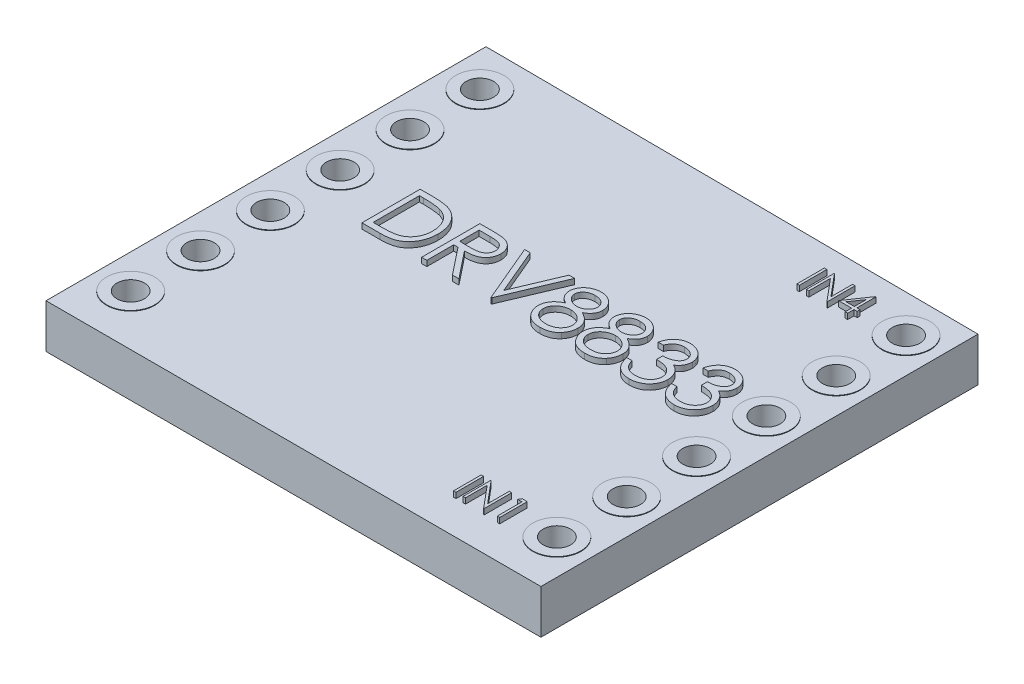
from build123d import *

# Parameters (mm, degrees)
SKETCH2_R           = 0.875
BOSS_EXTRUDE1_DEPTH = 1.6
SKETCH2_4_R         = 0.875
SKETCH2_4_R_2       = 0.5
BOSS_EXTRUDE2_DEPTH = 1.62
SKETCH3_W           = 0.08974359
SKETCH3_H           = 1
BOSS_EXTRUDE3_DEPTH = 0.2


with BuildPart() as part:
    # Sketch2 → Boss-Extrude1 (new body)
    with BuildSketch(Plane(origin=(0, 0, 0), x_dir=(1, 0, 0), z_dir=(0, 1, 0))):
        Polygon((59.478389543, 331.876942484), (41.982232799, 331.981060415), (41.478389543, 331.981060415), (41.478389543, 315.981060415), (59.478389543, 315.981060415), align=None)
        with Locations((42.728389543, 317.810394786)):
            Circle(SKETCH2_R, mode=Mode.SUBTRACT)
        with Locations((42.728389543, 320.350394786)):
            Circle(SKETCH2_R, mode=Mode.SUBTRACT)
        with Locations((42.728389543, 322.890394786)):
            Circle(SKETCH2_R, mode=Mode.SUBTRACT)
        with Locations((58.228389543, 317.810394786)):
            Circle(SKETCH2_R, mode=Mode.SUBTRACT)
        with Locations((58.228389543, 320.350394786)):
            Circle(SKETCH2_R, mode=Mode.SUBTRACT)
        with Locations((58.228389543, 322.890394786)):
            Circle(SKETCH2_R, mode=Mode.SUBTRACT)
        with Locations((42.728389543, 325.430394786)):
            Circle(SKETCH2_R, mode=Mode.SUBTRACT)
        with Locations((42.728389543, 327.970394786)):
            Circle(SKETCH2_R, mode=Mode.SUBTRACT)
        with Locations((42.728389543, 330.510394786)):
            Circle(SKETCH2_R, mode=Mode.SUBTRACT)
        with Locations((58.228389543, 325.430394786)):
            Circle(SKETCH2_R, mode=Mode.SUBTRACT)
        with Locations((58.228389543, 327.970394786)):
            Circle(SKETCH2_R, mode=Mode.SUBTRACT)
        with Locations((58.228389543, 330.510394786)):
            Circle(SKETCH2_R, mode=Mode.SUBTRACT)
    extrude(amount=BOSS_EXTRUDE1_DEPTH)

    # Sketch2_4 → Boss-Extrude2 (add)
    # profile 1 of 12: a face of its own
    with BuildSketch(Plane(origin=(0, 0, 0), x_dir=(1, 0, 0), z_dir=(0, 1, 0))):
        with Locations((42.728389543, 330.510394786)):
            Circle(SKETCH2_4_R)
        with Locations((42.728389543, 330.510394786)):
            Circle(SKETCH2_4_R_2, mode=Mode.SUBTRACT)
    # profile 2 of 12: a face of its own
    with BuildSketch(Plane(origin=(0, 0, 0), x_dir=(1, 0, 0), z_dir=(0, 1, 0))):
        with Locations((58.228389543, 330.510394786)):
            Circle(SKETCH2_4_R)
        with Locations((58.228389543, 330.510394786)):
            Circle(SKETCH2_4_R_2, mode=Mode.SUBTRACT)
    # profile 3 of 12: a face of its own
    with BuildSketch(Plane(origin=(0, 0, 0), x_dir=(1, 0, 0), z_dir=(0, 1, 0))):
        with Locations((58.228389543, 327.970394786)):
            Circle(SKETCH2_4_R)
        with Locations((58.228389543, 327.970394786)):
            Circle(SKETCH2_4_R_2, mode=Mode.SUBTRACT)
    # profile 4 of 12: a face of its own
    with BuildSketch(Plane(origin=(0, 0, 0), x_dir=(1, 0, 0), z_dir=(0, 1, 0))):
        with Locations((58.228389543, 325.430394786)):
            Circle(SKETCH2_4_R)
        with Locations((58.228389543, 325.430394786)):
            Circle(SKETCH2_4_R_2, mode=Mode.SUBTRACT)
    # profile 5 of 12: a face of its own
    with BuildSketch(Plane(origin=(0, 0, 0), x_dir=(1, 0, 0), z_dir=(0, 1, 0))):
        with Locations((58.228389543, 322.890394786)):
            Circle(SKETCH2_4_R)
        with Locations((58.228389543, 322.890394786)):
            Circle(SKETCH2_4_R_2, mode=Mode.SUBTRACT)
    # profile 6 of 12: a face of its own
    with BuildSketch(Plane(origin=(0, 0, 0), x_dir=(1, 0, 0), z_dir=(0, 1, 0))):
        with Locations((58.228389543, 320.350394786)):
            Circle(SKETCH2_4_R)
        with Locations((58.228389543, 320.350394786)):
            Circle(SKETCH2_4_R_2, mode=Mode.SUBTRACT)
    # profile 7 of 12: a face of its own
    with BuildSketch(Plane(origin=(0, 0, 0), x_dir=(1, 0, 0), z_dir=(0, 1, 0))):
        with Locations((58.228389543, 317.810394786)):
            Circle(SKETCH2_4_R)
        with Locations((58.228389543, 317.810394786)):
            Circle(SKETCH2_4_R_2, mode=Mode.SUBTRACT)
    # profile 8 of 12: a face of its own
    with BuildSketch(Plane(origin=(0, 0, 0), x_dir=(1, 0, 0), z_dir=(0, 1, 0))):
        with Locations((42.728389543, 327.970394786)):
            Circle(SKETCH2_4_R)
        with Locations((42.728389543, 327.970394786)):
            Circle(SKETCH2_4_R_2, mode=Mode.SUBTRACT)
    # profile 9 of 12: a face of its own
    with BuildSketch(Plane(origin=(0, 0, 0), x_dir=(1, 0, 0), z_dir=(0, 1, 0))):
        with Locations((42.728389543, 325.430394786)):
            Circle(SKETCH2_4_R)
        with Locations((42.728389543, 325.430394786)):
            Circle(SKETCH2_4_R_2, mode=Mode.SUBTRACT)
    # profile 10 of 12: a face of its own
    with BuildSketch(Plane(origin=(0, 0, 0), x_dir=(1, 0, 0), z_dir=(0, 1, 0))):
        with Locations((42.728389543, 322.890394786)):
            Circle(SKETCH2_4_R)
        with Locations((42.728389543, 322.890394786)):
            Circle(SKETCH2_4_R_2, mode=Mode.SUBTRACT)
    # profile 11 of 12: a face of its own
    with BuildSketch(Plane(origin=(0, 0, 0), x_dir=(1, 0, 0), z_dir=(0, 1, 0))):
        with Locations((42.728389543, 320.350394786)):
            Circle(SKETCH2_4_R)
        with Locations((42.728389543, 320.350394786)):
            Circle(SKETCH2_4_R_2, mode=Mode.SUBTRACT)
    # profile 12 of 12: a face of its own
    with BuildSketch(Plane(origin=(0, 0, 0), x_dir=(1, 0, 0), z_dir=(0, 1, 0))):
        with Locations((42.728389543, 317.810394786)):
            Circle(SKETCH2_4_R)
        with Locations((42.728389543, 317.810394786)):
            Circle(SKETCH2_4_R_2, mode=Mode.SUBTRACT)
    extrude(amount=BOSS_EXTRUDE2_DEPTH)

    # Sketch3 → Boss-Extrude3 (add)
    # profile 1 of 13: a face of its own
    with BuildSketch(Plane(origin=(0, 1.6, 0), x_dir=(1, 0, 0), z_dir=(0, 1, 0))):
        with BuildLine():
            Line((44.96926465, 323.980868602), (44.96926465, 326.097535269))
            Line((44.96926465, 326.097535269), (45.396668496, 326.097535269))
            add(Edge.make_bspline(
                [(45.396668496, 326.097535269), (45.433842598, 326.09726762), (45.505662771, 326.096750522), (45.609447441, 326.093471871), (45.705473812, 326.087671923), (45.793426065, 326.079223686), (45.873545655, 326.068850184), (45.945608242, 326.055847559), (46.009986442, 326.040493761), (46.049579866, 326.027403417), (46.068303111, 326.021213154)],
                knots=[0, 0, 0, 0, 1.314313732, 2.53924729, 3.670748893, 4.714932338, 5.66265055, 6.526160246, 7.303039223, 8, 8, 8, 8], degree=3))
            add(Edge.make_bspline(
                [(46.068303111, 326.021213154), (46.092792787, 326.011881251), (46.141216794, 325.993429061), (46.210163958, 325.958621203), (46.275070249, 325.919182803), (46.336283732, 325.875061877), (46.392406137, 325.825009152), (46.44562996, 325.771150819), (46.493777912, 325.711528347), (46.537870072, 325.647378235), (46.577624495, 325.579456184), (46.61218008, 325.507891619), (46.640878448, 325.433047974), (46.664701971, 325.355133384), (46.683477685, 325.273976527), (46.696287711, 325.189482903), (46.704736833, 325.101986441), (46.70558595, 325.042614266), (46.706016786, 325.012489195)],
                knots=[0, 0, 0, 0, 0.984719456, 1.947108742, 2.898477687, 3.838006223, 4.779231079, 5.722358779, 6.681677486, 7.655904652, 8.64651281, 9.637519902, 10.640069247, 11.656948941, 12.698408672, 13.768548281, 14.867775369, 16, 16, 16, 16], degree=3))
            add(Edge.make_bspline(
                [(46.706016786, 325.012489195), (46.705636411, 324.986326446), (46.704886841, 324.934770017), (46.698156255, 324.858787189), (46.688373433, 324.785058506), (46.673227656, 324.713935059), (46.654841374, 324.644793708), (46.63127734, 324.578371351), (46.604283492, 324.514058666), (46.572805708, 324.45272524), (46.538248775, 324.394617677), (46.501163721, 324.339841048), (46.461590101, 324.289176985), (46.419150551, 324.242472063), (46.374393504, 324.199796689), (46.327025932, 324.160794375), (46.276925611, 324.126228268), (46.224316936, 324.094740064), (46.167665182, 324.067271564), (46.105897301, 324.044030558), (46.038749874, 324.024770938), (45.966387719, 324.008701872), (45.888685806, 323.995955123), (45.805567956, 323.987412019), (45.717161871, 323.981634769), (45.656456315, 323.98112895), (45.62521083, 323.980868602)],
                knots=[0, 0, 0, 0, 1.105936401, 2.179363191, 3.223086493, 4.248585256, 5.251745608, 6.245858792, 7.225916811, 8.198733463, 9.158002045, 10.082870192, 10.993790845, 11.873723703, 12.748670949, 13.606408763, 14.465103618, 15.319838547, 16.196477973, 17.123216899, 18.106603292, 19.147568657, 20.255746949, 21.433717677, 22.679120308, 24, 24, 24, 24], degree=3))
            Line((45.62521083, 323.980868602), (44.96926465, 323.980868602))
        make_face()
        with BuildLine():
            Line((45.159221915, 324.197962619), (45.402180649, 324.197962619))
            add(Edge.make_bspline(
                [(45.402180649, 324.197962619), (45.437092568, 324.198112659), (45.504240975, 324.198401239), (45.600796049, 324.2009335), (45.689018351, 324.205071243), (45.768920407, 324.210861885), (45.840457102, 324.218523381), (45.903777942, 324.227065584), (45.95867536, 324.237707852), (45.991894591, 324.247354385), (46.007245419, 324.251812112)],
                knots=[0, 0, 0, 0, 1.375205317, 2.645023457, 3.804390687, 4.853969522, 5.800190428, 6.637939096, 7.370582563, 8, 8, 8, 8], degree=3))
            add(Edge.make_bspline(
                [(46.007245419, 324.251812112), (46.026566571, 324.258616626), (46.064747391, 324.272063128), (46.119708809, 324.296590856), (46.170966616, 324.32564487), (46.219414108, 324.357940531), (46.264364038, 324.394616922), (46.306349098, 324.43487652), (46.345284759, 324.478924218), (46.380768745, 324.526705344), (46.412523767, 324.577922506), (46.440023035, 324.632072182), (46.464123723, 324.688561062), (46.483039824, 324.748256601), (46.497865915, 324.810625127), (46.508367417, 324.875671027), (46.514907751, 324.943382155), (46.515670626, 324.989436058), (46.516059522, 325.012913207)],
                knots=[0, 0, 0, 0, 0.998632004, 1.973411704, 2.929992603, 3.868527914, 4.809262121, 5.754881198, 6.702106254, 7.672490631, 8.653608572, 9.636854334, 10.631411391, 11.644891563, 12.686317037, 13.754757253, 14.855430412, 16, 16, 16, 16], degree=3))
            add(Edge.make_bspline(
                [(46.516059522, 325.012913207), (46.515749105, 325.037668217), (46.515139289, 325.086299652), (46.507474349, 325.157655929), (46.496273217, 325.226284704), (46.480075464, 325.292190565), (46.459434409, 325.355502092), (46.433674792, 325.415869129), (46.404243075, 325.473929217), (46.369225343, 325.528342285), (46.330874008, 325.579803356), (46.288312147, 325.626947519), (46.242215962, 325.669882168), (46.19308822, 325.709275942), (46.139544355, 325.743543975), (46.082845694, 325.774197349), (46.022160455, 325.800211721), (45.979940396, 325.814047986), (45.958484067, 325.821079607)],
                knots=[0, 0, 0, 0, 1.122418816, 2.205001699, 3.251619955, 4.274784885, 5.280384055, 6.268708349, 7.249350384, 8.229342522, 9.199999885, 10.157847722, 11.105861043, 12.055065948, 13.010012805, 13.98527497, 14.976112212, 16, 16, 16, 16], degree=3))
            add(Edge.make_bspline(
                [(45.958484067, 325.821079607), (45.940733612, 325.825988113), (45.902991274, 325.836424944), (45.841402646, 325.847809812), (45.77208777, 325.857851581), (45.694738903, 325.866353348), (45.609444216, 325.872453775), (45.516138109, 325.877032618), (45.414780253, 325.880120915), (45.344517483, 325.8803318), (45.30805004, 325.880441252)],
                knots=[0, 0, 0, 0, 0.674548936, 1.434276114, 2.292660221, 3.240891867, 4.284742987, 5.42552168, 6.663806718, 8, 8, 8, 8], degree=3))
            Line((45.30805004, 325.880441252), (45.159221915, 325.880441252))
            Line((45.159221915, 325.880441252), (45.159221915, 324.197962619))
        make_face(mode=Mode.SUBTRACT)
    # profile 2 of 13: a face of its own
    with BuildSketch(Plane(origin=(0, 1.6, 0), x_dir=(1, 0, 0), z_dir=(0, 1, 0))):
        with BuildLine():
            Line((47.140204821, 326.097535269), (47.563792561, 326.097535269))
            add(Edge.make_bspline(
                [(47.563792561, 326.097535269), (47.592059815, 326.097441177), (47.646336074, 326.097260509), (47.72409229, 326.096253119), (47.794744867, 326.09336577), (47.858256865, 326.090881055), (47.914627119, 326.086350215), (47.96402848, 326.082019728), (48.006233421, 326.076350895), (48.031782103, 326.071086187), (48.043349853, 326.06870247)],
                knots=[0, 0, 0, 0, 1.410062039, 2.707475311, 3.878576406, 4.937260626, 5.877586885, 6.699081471, 7.410979367, 8, 8, 8, 8], degree=3))
            add(Edge.make_bspline(
                [(48.043349853, 326.06870247), (48.058835763, 326.064876283), (48.089477229, 326.057305533), (48.133594649, 326.041303774), (48.175634264, 326.022786192), (48.215421444, 326.001036704), (48.252756899, 325.975893861), (48.288025591, 325.947791711), (48.321387562, 325.916884019), (48.351493595, 325.88239152), (48.379880546, 325.846204678), (48.403822239, 325.807074311), (48.424460634, 325.766155197), (48.440892327, 325.723031187), (48.454123292, 325.678120497), (48.463452494, 325.63101632), (48.46904726, 325.581933254), (48.469616858, 325.548454899), (48.469905675, 325.53147958)],
                knots=[0, 0, 0, 0, 1.027469482, 2.033020251, 3.019912614, 3.986113645, 4.951240523, 5.91722682, 6.890402269, 7.87763091, 8.8651537, 9.85103654, 10.82876324, 11.815024772, 12.821070561, 13.842952187, 14.906261191, 16, 16, 16, 16], degree=3))
            add(Edge.make_bspline(
                [(48.469905675, 325.53147958), (48.469017281, 325.503276445), (48.467283794, 325.448244825), (48.45112147, 325.368379434), (48.424647098, 325.29387923), (48.388165871, 325.224838016), (48.341708379, 325.162601578), (48.285873862, 325.107936874), (48.220631173, 325.062192736), (48.159895349, 325.030471278), (48.10624438, 325.010155567), (48.062076615, 324.995861197), (48.013897062, 324.984817056), (47.962167341, 324.974923072), (47.906672178, 324.967453238), (47.847544582, 324.961982202), (47.784742386, 324.958562849), (47.741599234, 324.958053636), (47.719404874, 324.957791679)],
                knots=[0, 0, 0, 0, 1.260483769, 2.459530307, 3.627416485, 4.787058657, 5.939039949, 7.08810263, 8.267026773, 9.491475466, 10.141966685, 10.831826277, 11.566392101, 12.351337768, 13.187381173, 14.07005841, 15.007169909, 16, 16, 16, 16], degree=3))
            Line((47.719404874, 324.957791679), (48.497042427, 323.980868602))
            Line((48.497042427, 323.980868602), (48.262139917, 323.980868602))
            Line((48.262139917, 323.980868602), (47.484502363, 324.957791679))
            Line((47.484502363, 324.957791679), (47.330162086, 324.957791679))
            Line((47.330162086, 324.957791679), (47.330162086, 323.980868602))
            Line((47.330162086, 323.980868602), (47.140204821, 323.980868602))
            Line((47.140204821, 323.980868602), (47.140204821, 326.097535269))
        make_face()
        with BuildLine():
            Line((47.330162086, 325.880441252), (47.330162086, 325.174885696))
            Line((47.330162086, 325.174885696), (47.717708827, 325.171917614))
            add(Edge.make_bspline(
                [(47.717708827, 325.171917614), (47.735803327, 325.171909609), (47.770875621, 325.171894093), (47.821615547, 325.174309377), (47.868859614, 325.177057003), (47.912427117, 325.181259702), (47.952337517, 325.186675993), (47.988570867, 325.193451131), (48.021186313, 325.201344521), (48.059224953, 325.213561695), (48.101701331, 325.232917716), (48.14786369, 325.261078755), (48.187174628, 325.296499127), (48.220386859, 325.337002122), (48.247074658, 325.38153452), (48.265890043, 325.429562515), (48.27782952, 325.479873624), (48.279237736, 325.514452766), (48.27994841, 325.531903592)],
                knots=[0, 0, 0, 0, 1.146690395, 2.22261258, 3.21895312, 4.145990853, 4.996080663, 5.770904154, 6.481378293, 7.121626537, 8.300444488, 9.431385265, 10.535395872, 11.636531494, 12.74115979, 13.810798291, 14.895190096, 16, 16, 16, 16], degree=3))
            add(Edge.make_bspline(
                [(48.27994841, 325.531903592), (48.279221413, 325.548925567), (48.277780771, 325.582656912), (48.266018896, 325.632039295), (48.246128651, 325.678646451), (48.21932425, 325.722288782), (48.186667618, 325.761904156), (48.148375417, 325.795799339), (48.105494657, 325.823769253), (48.06541636, 325.841642617), (48.029593765, 325.852600814), (47.998491066, 325.860312232), (47.963347458, 325.866507696), (47.9239923, 325.871471619), (47.880593599, 325.87573818), (47.83293192, 325.878611875), (47.781323486, 325.880313593), (47.745553675, 325.880397709), (47.727037086, 325.880441252)],
                knots=[0, 0, 0, 0, 1.101028733, 2.181837193, 3.264309656, 4.369019818, 5.486613113, 6.575447106, 7.666700264, 8.788928104, 9.402425223, 10.0903467, 10.862060571, 11.710948788, 12.657782767, 13.684531032, 14.801375019, 16, 16, 16, 16], degree=3))
            Line((47.727037086, 325.880441252), (47.330162086, 325.880441252))
        make_face(mode=Mode.SUBTRACT)
    # profile 3 of 13: a face of its own
    with BuildSketch(Plane(origin=(0, 1.6, 0), x_dir=(1, 0, 0), z_dir=(0, 1, 0))):
        Polygon((48.768409949, 326.097535269), (48.97193559, 326.097535269), (49.677491145, 324.429473036), (50.383046701, 326.097535269), (50.586572342, 326.097535269), (49.691059522, 323.980868602), (49.663922769, 323.980868602), align=None)
    # profile 4 of 13: a face of its own
    with BuildSketch(Plane(origin=(0, 1.6, 0), x_dir=(1, 0, 0), z_dir=(0, 1, 0))):
        with BuildLine():
            add(Edge.make_bspline(
                [(51.805606129, 325.160045285), (51.822931679, 325.151011378), (51.856722288, 325.133392243), (51.904847552, 325.105022362), (51.948828862, 325.07512235), (51.989886488, 325.045104473), (52.027299086, 325.013819141), (52.060648326, 324.981141946), (52.090757982, 324.947888541), (52.117020846, 324.913495828), (52.140120838, 324.878055179), (52.16008532, 324.841473571), (52.177150009, 324.803831174), (52.190674262, 324.764717091), (52.20181506, 324.724705885), (52.209480783, 324.683280915), (52.213603395, 324.640715147), (52.214382821, 324.61194765), (52.21477747, 324.59738169)],
                knots=[0, 0, 0, 0, 1.272397273, 2.481599622, 3.635517121, 4.734568067, 5.792894095, 6.808321871, 7.773003508, 8.711915296, 9.623354172, 10.525449501, 11.423591555, 12.311487226, 13.218079475, 14.126165749, 15.051214107, 16, 16, 16, 16], degree=3))
            add(Edge.make_bspline(
                [(52.21477747, 324.59738169), (52.214310944, 324.577002585), (52.213387515, 324.53666469), (52.205344191, 324.477128232), (52.19330158, 324.419305868), (52.175715399, 324.363210276), (52.152907777, 324.309150989), (52.124800357, 324.25708173), (52.092983105, 324.206149101), (52.06743056, 324.174810701), (52.054501028, 324.158953538)],
                knots=[0, 0, 0, 0, 1.025265484, 2.029385089, 3.018602448, 3.995076438, 4.983346944, 5.966715145, 6.97116228, 8, 8, 8, 8], degree=3))
            add(Edge.make_bspline(
                [(52.054501028, 324.158953538), (52.037666589, 324.140451589), (52.004205738, 324.103676325), (51.946884634, 324.055929882), (51.883976162, 324.015804296), (51.815723741, 323.983103674), (51.742309818, 323.95765175), (51.663750034, 323.939362227), (51.579891237, 323.928886282), (51.522254119, 323.927371965), (51.492685456, 323.926595098)],
                knots=[0, 0, 0, 0, 0.954267603, 1.896743057, 2.838368354, 3.796610408, 4.779680527, 5.799409237, 6.871065594, 8, 8, 8, 8], degree=3))
            add(Edge.make_bspline(
                [(51.492685456, 323.926595098), (51.46425355, 323.927292073), (51.408927948, 323.928648315), (51.328399136, 323.937837328), (51.253334232, 323.953940848), (51.183296775, 323.975981159), (51.118708994, 324.004653059), (51.059754928, 324.040339097), (51.005584002, 324.081602874), (50.957840182, 324.129629483), (50.915453361, 324.181069244), (50.878219348, 324.234138074), (50.847271215, 324.288840819), (50.821068638, 324.344361813), (50.801009882, 324.401479249), (50.787117164, 324.459899257), (50.778294103, 324.519519795), (50.777120178, 324.559755605), (50.776529607, 324.579997208)],
                knots=[0, 0, 0, 0, 1.256902934, 2.445805442, 3.576955095, 4.645999104, 5.686449165, 6.692658513, 7.68621702, 8.689161843, 9.678783111, 10.630372946, 11.551080876, 12.453998257, 13.34127905, 14.221779781, 15.105423033, 16, 16, 16, 16], degree=3))
            add(Edge.make_bspline(
                [(50.776529607, 324.579997208), (50.776879087, 324.594849672), (50.777569784, 324.624203383), (50.782350335, 324.667570453), (50.790035928, 324.709780496), (50.80047379, 324.750989422), (50.814619792, 324.79089722), (50.831699558, 324.829692983), (50.851615549, 324.867420509), (50.874645587, 324.904286118), (50.901437763, 324.939773252), (50.931774827, 324.974484163), (50.96626311, 325.007880244), (51.004518932, 325.04036952), (51.046105106, 325.072528324), (51.092101803, 325.102618693), (51.14128967, 325.132770891), (51.176248177, 325.15079783), (51.194181183, 325.160045285)],
                knots=[0, 0, 0, 0, 0.941657376, 1.861047343, 2.762797495, 3.66048619, 4.553285746, 5.444104102, 6.34607688, 7.256116206, 8.197091036, 9.162375105, 10.176350973, 11.237807142, 12.343728897, 13.50695164, 14.721116704, 16, 16, 16, 16], degree=3))
            add(Edge.make_bspline(
                [(51.194181183, 325.160045285), (51.169633066, 325.17343155), (51.12210104, 325.199351105), (51.059163807, 325.246974174), (51.005103763, 325.298552995), (50.961406862, 325.355176728), (50.927012705, 325.415076505), (50.90341574, 325.477877552), (50.887452152, 325.542415393), (50.885870804, 325.586506283), (50.885076616, 325.608649719)],
                knots=[0, 0, 0, 0, 1.166880483, 2.259407225, 3.286803203, 4.280235371, 5.237608625, 6.161067461, 7.076446754, 8, 8, 8, 8], degree=3))
            add(Edge.make_bspline(
                [(50.885076616, 325.608649719), (50.886065658, 325.631205861), (50.888053805, 325.676547641), (50.904130385, 325.744042773), (50.930328711, 325.810334696), (50.965961885, 325.875102103), (51.010343678, 325.936152947), (51.063590874, 325.990908662), (51.124431916, 326.038873225), (51.192563102, 326.079135958), (51.265882159, 326.111904171), (51.343240716, 326.134509217), (51.423290928, 326.14928725), (51.477778597, 326.150960417), (51.505405809, 326.151808773)],
                knots=[0, 0, 0, 0, 0.888701115, 1.786444228, 2.72001202, 3.692817113, 4.693886446, 5.687152267, 6.695133018, 7.739871481, 8.800368666, 9.853104506, 10.91144658, 12, 12, 12, 12], degree=3))
            add(Edge.make_bspline(
                [(51.505405809, 326.151808773), (51.532320021, 326.15093408), (51.585391781, 326.149209285), (51.663402817, 326.134823887), (51.738045481, 326.110796987), (51.809062369, 326.078202), (51.875182117, 326.038053707), (51.933603514, 325.989430321), (51.985209408, 325.934916145), (52.027896161, 325.873883814), (52.063070861, 325.809365277), (52.087564263, 325.741860229), (52.103259028, 325.672827227), (52.105238634, 325.626116624), (52.106230462, 325.602713554)],
                knots=[0, 0, 0, 0, 1.072916533, 2.115669174, 3.151510826, 4.193348718, 5.225979165, 6.227137561, 7.216255879, 8.211077061, 9.189680878, 10.138522389, 11.067357538, 12, 12, 12, 12], degree=3))
            add(Edge.make_bspline(
                [(52.106230462, 325.602713554), (52.105362894, 325.579746715), (52.103659041, 325.534641147), (52.08932622, 325.46888749), (52.065188168, 325.407309399), (52.032232175, 325.349208138), (51.989278666, 325.295637423), (51.936901003, 325.245916034), (51.875516776, 325.199635523), (51.829397097, 325.173518055), (51.805606129, 325.160045285)],
                knots=[0, 0, 0, 0, 0.975232327, 1.915300861, 2.843280834, 3.77672583, 4.742871857, 5.749627742, 6.839139064, 8, 8, 8, 8], degree=3))
        make_face()
        with BuildLine():
            add(Edge.make_bspline(
                [(51.494805515, 325.934714756), (51.479958123, 325.93432079), (51.450910132, 325.933550019), (51.408317555, 325.929523129), (51.367815218, 325.921689517), (51.328979948, 325.911264201), (51.29234419, 325.897180513), (51.257410388, 325.880613055), (51.224773088, 325.860470815), (51.1940383, 325.837876186), (51.166369974, 325.813024762), (51.141813888, 325.787132656), (51.12141641, 325.759691347), (51.104095358, 325.731383435), (51.091527488, 325.701368753), (51.08211479, 325.670567518), (51.075751853, 325.6385905), (51.075275065, 325.616736515), (51.07503388, 325.605681637)],
                knots=[0, 0, 0, 0, 1.203892937, 2.355340988, 3.463153438, 4.544400666, 5.610487187, 6.640501085, 7.674077295, 8.714426146, 9.728707835, 10.68524104, 11.601827946, 12.495867327, 13.368432065, 14.231010473, 15.105153427, 16, 16, 16, 16], degree=3))
            add(Edge.make_bspline(
                [(51.07503388, 325.605681637), (51.075449574, 325.594626281), (51.076271044, 325.57277931), (51.082624145, 325.540517762), (51.092092814, 325.508815153), (51.107000595, 325.478425317), (51.124881202, 325.448294047), (51.146949857, 325.419174407), (51.173250364, 325.390965055), (51.202900292, 325.363905926), (51.235201556, 325.338567151), (51.269421429, 325.316570036), (51.305130438, 325.298164645), (51.341961689, 325.282846386), (51.380290559, 325.270938662), (51.419882189, 325.262490957), (51.460743231, 325.257240416), (51.488429582, 325.256613265), (51.502437727, 325.256295953)],
                knots=[0, 0, 0, 0, 0.873023192, 1.725219244, 2.590779336, 3.480155217, 4.391973325, 5.357036234, 6.360879153, 7.436073238, 8.526419356, 9.601555421, 10.645666583, 11.697338044, 12.750135903, 13.812665442, 14.89329948, 16, 16, 16, 16], degree=3))
            add(Edge.make_bspline(
                [(51.502437727, 325.256295953), (51.520429456, 325.25682383), (51.556235212, 325.257874369), (51.609018427, 325.267641984), (51.660340121, 325.283006515), (51.709651744, 325.304028019), (51.755676898, 325.330412486), (51.796703987, 325.362001026), (51.83238306, 325.398064246), (51.862343334, 325.438040723), (51.885572146, 325.480586684), (51.90365562, 325.523283051), (51.914215498, 325.566585353), (51.915592884, 325.595593945), (51.916273197, 325.609921754)],
                knots=[0, 0, 0, 0, 1.076279235, 2.141928126, 3.20205304, 4.278698113, 5.344010996, 6.36967002, 7.368914609, 8.37248503, 9.349703398, 10.264243087, 11.142681841, 12, 12, 12, 12], degree=3))
            add(Edge.make_bspline(
                [(51.916273197, 325.609921754), (51.915951525, 325.619977757), (51.915313054, 325.639937481), (51.910051591, 325.669412587), (51.901357635, 325.698217145), (51.889587106, 325.726589109), (51.874099278, 325.754130409), (51.855736174, 325.78127399), (51.833429832, 325.807409238), (51.808394846, 325.833145213), (51.780004052, 325.85696317), (51.748312162, 325.877908923), (51.713481656, 325.895696396), (51.67551171, 325.910143405), (51.63454216, 325.920994254), (51.590761708, 325.929120046), (51.543805304, 325.933699975), (51.511493026, 325.934369159), (51.494805515, 325.934714756)],
                knots=[0, 0, 0, 0, 0.814439003, 1.616544685, 2.417341072, 3.248991801, 4.09997495, 4.973547432, 5.9003056, 6.880240646, 7.880314356, 8.896779544, 9.951930927, 11.043077905, 12.18215768, 13.381699519, 14.647792085, 16, 16, 16, 16], degree=3))
        make_face(mode=Mode.SUBTRACT)
        with BuildLine():
            add(Edge.make_bspline(
                [(51.507101856, 325.039201936), (51.488278167, 325.038867114), (51.451350681, 325.038210277), (51.397250539, 325.030899008), (51.345329815, 325.020721232), (51.295763568, 325.005281153), (51.248572728, 324.985205181), (51.20350183, 324.961054292), (51.16089567, 324.932506238), (51.121342593, 324.899923714), (51.085224198, 324.864811568), (51.053535703, 324.82764161), (51.026625298, 324.78910465), (51.004954712, 324.748711254), (50.987167617, 324.707316746), (50.97548732, 324.663890248), (50.967999333, 324.619266613), (50.966993836, 324.588931696), (50.966486872, 324.573637032)],
                knots=[0, 0, 0, 0, 1.140299081, 2.23698856, 3.303958914, 4.344563908, 5.37730929, 6.408454204, 7.439741482, 8.480804886, 9.510774543, 10.48932336, 11.43758569, 12.353841022, 13.263987381, 14.161954604, 15.073269652, 16, 16, 16, 16], degree=3))
            add(Edge.make_bspline(
                [(50.966486872, 324.573637032), (50.967311319, 324.554628817), (50.968947002, 324.516916963), (50.98192316, 324.461180249), (51.00274846, 324.407222754), (51.031792281, 324.355484192), (51.067756004, 324.307133413), (51.111980106, 324.264988297), (51.161716232, 324.227540545), (51.218647219, 324.197253747), (51.280833958, 324.173066382), (51.348259909, 324.156401585), (51.419957407, 324.145369851), (51.46946297, 324.144258189), (51.494805515, 324.143689115)],
                knots=[0, 0, 0, 0, 0.898778495, 1.783155532, 2.693654817, 3.627872908, 4.583023416, 5.533784346, 6.509005473, 7.520592997, 8.575161974, 9.658835044, 10.801527049, 12, 12, 12, 12], degree=3))
            add(Edge.make_bspline(
                [(51.494805515, 324.143689115), (51.51461169, 324.144069395), (51.55320047, 324.144810301), (51.609495306, 324.151350374), (51.662620342, 324.161721814), (51.712472559, 324.17680672), (51.759610024, 324.195221706), (51.803233528, 324.218911488), (51.844465304, 324.245855036), (51.881273607, 324.277821636), (51.9147975, 324.311978282), (51.944027634, 324.348137023), (51.969401962, 324.385315143), (51.98931735, 324.424352817), (52.005238465, 324.464501094), (52.01668271, 324.506130189), (52.02374404, 324.549367782), (52.024458201, 324.578698173), (52.024820205, 324.593565584)],
                knots=[0, 0, 0, 0, 1.224942928, 2.386581632, 3.501229538, 4.569074225, 5.605009692, 6.626002462, 7.634866581, 8.645888296, 9.63523824, 10.59253846, 11.518950513, 12.414518923, 13.29783783, 14.186679152, 15.080837789, 16, 16, 16, 16], degree=3))
            add(Edge.make_bspline(
                [(52.024820205, 324.593565584), (52.024272383, 324.60800569), (52.023192172, 324.636479057), (52.016336173, 324.678671194), (52.004291809, 324.719433849), (51.987765241, 324.759257424), (51.96576342, 324.797335018), (51.939852475, 324.834658607), (51.908589841, 324.870192266), (51.873264128, 324.904211996), (51.834765614, 324.935669132), (51.793843103, 324.963496911), (51.750811595, 324.986932715), (51.705762148, 325.005992691), (51.658794793, 325.020983208), (51.609944074, 325.031455262), (51.559152798, 325.038046927), (51.524648186, 325.038812583), (51.507101856, 325.039201936)],
                knots=[0, 0, 0, 0, 0.917430815, 1.809013306, 2.70690318, 3.612392954, 4.541220862, 5.495268465, 6.494511384, 7.542276156, 8.608045339, 9.649016899, 10.681629292, 11.715607085, 12.752076957, 13.808767841, 14.885711793, 16, 16, 16, 16], degree=3))
        make_face(mode=Mode.SUBTRACT)
    # profile 5 of 13: a face of its own
    with BuildSketch(Plane(origin=(0, 1.6, 0), x_dir=(1, 0, 0), z_dir=(0, 1, 0))):
        with BuildLine():
            add(Edge.make_bspline(
                [(53.433811258, 325.160045285), (53.451136808, 325.151011378), (53.484927416, 325.133392243), (53.53305268, 325.105022362), (53.57703399, 325.07512235), (53.618091616, 325.045104473), (53.655504214, 325.013819141), (53.688853454, 324.981141946), (53.71896311, 324.947888541), (53.745225974, 324.913495828), (53.768325966, 324.878055179), (53.788290448, 324.841473571), (53.805355137, 324.803831174), (53.818879391, 324.764717091), (53.830020188, 324.724705885), (53.837685911, 324.683280915), (53.841808524, 324.640715147), (53.842587949, 324.61194765), (53.842982598, 324.59738169)],
                knots=[0, 0, 0, 0, 1.272397273, 2.481599622, 3.635517121, 4.734568067, 5.792894095, 6.808321871, 7.773003508, 8.711915296, 9.623354172, 10.525449501, 11.423591555, 12.311487226, 13.218079475, 14.126165749, 15.051214107, 16, 16, 16, 16], degree=3))
            add(Edge.make_bspline(
                [(53.842982598, 324.59738169), (53.842516073, 324.577002585), (53.841592643, 324.53666469), (53.833549319, 324.477128232), (53.821506709, 324.419305868), (53.803920527, 324.363210276), (53.781112905, 324.309150989), (53.753005486, 324.25708173), (53.721188233, 324.206149101), (53.695635688, 324.174810701), (53.682706156, 324.158953538)],
                knots=[0, 0, 0, 0, 1.025265484, 2.029385089, 3.018602448, 3.995076438, 4.983346944, 5.966715145, 6.97116228, 8, 8, 8, 8], degree=3))
            add(Edge.make_bspline(
                [(53.682706156, 324.158953538), (53.665871717, 324.140451589), (53.632410866, 324.103676325), (53.575089762, 324.055929882), (53.51218129, 324.015804296), (53.44392887, 323.983103674), (53.370514946, 323.95765175), (53.291955163, 323.939362227), (53.208096365, 323.928886282), (53.150459247, 323.927371965), (53.120890585, 323.926595098)],
                knots=[0, 0, 0, 0, 0.954267603, 1.896743057, 2.838368354, 3.796610408, 4.779680527, 5.799409237, 6.871065594, 8, 8, 8, 8], degree=3))
            add(Edge.make_bspline(
                [(53.120890585, 323.926595098), (53.092458678, 323.927292073), (53.037133076, 323.928648315), (52.956604264, 323.937837328), (52.88153936, 323.953940848), (52.811501903, 323.975981159), (52.746914122, 324.004653059), (52.687960056, 324.040339097), (52.63378913, 324.081602874), (52.58604531, 324.129629483), (52.543658489, 324.181069244), (52.506424476, 324.234138074), (52.475476343, 324.288840819), (52.449273766, 324.344361813), (52.42921501, 324.401479249), (52.415322292, 324.459899257), (52.406499231, 324.519519795), (52.405325306, 324.559755605), (52.404734735, 324.579997208)],
                knots=[0, 0, 0, 0, 1.256902934, 2.445805442, 3.576955095, 4.645999104, 5.686449165, 6.692658513, 7.68621702, 8.689161843, 9.678783111, 10.630372946, 11.551080876, 12.453998257, 13.34127905, 14.221779781, 15.105423033, 16, 16, 16, 16], degree=3))
            add(Edge.make_bspline(
                [(52.404734735, 324.579997208), (52.405084216, 324.594849672), (52.405774912, 324.624203383), (52.410555463, 324.667570453), (52.418241057, 324.709780496), (52.428678919, 324.750989422), (52.44282492, 324.79089722), (52.459904687, 324.829692983), (52.479820677, 324.867420509), (52.502850715, 324.904286118), (52.529642891, 324.939773252), (52.559979956, 324.974484163), (52.594468238, 325.007880244), (52.63272406, 325.04036952), (52.674310234, 325.072528324), (52.720306931, 325.102618693), (52.769494798, 325.132770891), (52.804453305, 325.15079783), (52.822386311, 325.160045285)],
                knots=[0, 0, 0, 0, 0.941657376, 1.861047343, 2.762797495, 3.66048619, 4.553285746, 5.444104102, 6.34607688, 7.256116206, 8.197091036, 9.162375105, 10.176350973, 11.237807142, 12.343728897, 13.50695164, 14.721116704, 16, 16, 16, 16], degree=3))
            add(Edge.make_bspline(
                [(52.822386311, 325.160045285), (52.797838194, 325.17343155), (52.750306168, 325.199351105), (52.687368935, 325.246974174), (52.633308891, 325.298552995), (52.589611991, 325.355176728), (52.555217834, 325.415076505), (52.531620868, 325.477877552), (52.51565728, 325.542415393), (52.514075932, 325.586506283), (52.513281744, 325.608649719)],
                knots=[0, 0, 0, 0, 1.166880483, 2.259407225, 3.286803203, 4.280235371, 5.237608625, 6.161067461, 7.076446754, 8, 8, 8, 8], degree=3))
            add(Edge.make_bspline(
                [(52.513281744, 325.608649719), (52.514270786, 325.631205861), (52.516258933, 325.676547641), (52.532335513, 325.744042773), (52.558533839, 325.810334696), (52.594167013, 325.875102103), (52.638548806, 325.936152947), (52.691796003, 325.990908662), (52.752637044, 326.038873225), (52.82076823, 326.079135958), (52.894087287, 326.111904171), (52.971445844, 326.134509217), (53.051496056, 326.14928725), (53.105983725, 326.150960417), (53.133610937, 326.151808773)],
                knots=[0, 0, 0, 0, 0.888701115, 1.786444228, 2.72001202, 3.692817113, 4.693886446, 5.687152267, 6.695133018, 7.739871481, 8.800368666, 9.853104506, 10.91144658, 12, 12, 12, 12], degree=3))
            add(Edge.make_bspline(
                [(53.133610937, 326.151808773), (53.160525149, 326.15093408), (53.213596909, 326.149209285), (53.291607945, 326.134823887), (53.366250609, 326.110796987), (53.437267497, 326.078202), (53.503387245, 326.038053707), (53.561808642, 325.989430321), (53.613414537, 325.934916145), (53.656101289, 325.873883814), (53.691275989, 325.809365277), (53.715769391, 325.741860229), (53.731464156, 325.672827227), (53.733443762, 325.626116624), (53.73443559, 325.602713554)],
                knots=[0, 0, 0, 0, 1.072916533, 2.115669174, 3.151510826, 4.193348718, 5.225979165, 6.227137561, 7.216255879, 8.211077061, 9.189680878, 10.138522389, 11.067357538, 12, 12, 12, 12], degree=3))
            add(Edge.make_bspline(
                [(53.73443559, 325.602713554), (53.733568022, 325.579746715), (53.731864169, 325.534641147), (53.717531348, 325.46888749), (53.693393297, 325.407309399), (53.660437303, 325.349208138), (53.617483794, 325.295637423), (53.565106131, 325.245916034), (53.503721904, 325.199635523), (53.457602225, 325.173518055), (53.433811258, 325.160045285)],
                knots=[0, 0, 0, 0, 0.975232327, 1.915300861, 2.843280834, 3.77672583, 4.742871857, 5.749627742, 6.839139064, 8, 8, 8, 8], degree=3))
        make_face()
        with BuildLine():
            add(Edge.make_bspline(
                [(53.123010643, 325.934714756), (53.108163251, 325.93432079), (53.07911526, 325.933550019), (53.036522683, 325.929523129), (52.996020346, 325.921689517), (52.957185077, 325.911264201), (52.920549319, 325.897180513), (52.885615517, 325.880613055), (52.852978216, 325.860470815), (52.822243428, 325.837876186), (52.794575103, 325.813024762), (52.770019017, 325.787132656), (52.749621538, 325.759691347), (52.732300486, 325.731383435), (52.719732616, 325.701368753), (52.710319918, 325.670567518), (52.703956981, 325.6385905), (52.703480193, 325.616736515), (52.703239009, 325.605681637)],
                knots=[0, 0, 0, 0, 1.203892937, 2.355340988, 3.463153438, 4.544400666, 5.610487187, 6.640501085, 7.674077295, 8.714426146, 9.728707835, 10.68524104, 11.601827946, 12.495867327, 13.368432065, 14.231010473, 15.105153427, 16, 16, 16, 16], degree=3))
            add(Edge.make_bspline(
                [(52.703239009, 325.605681637), (52.703654702, 325.594626281), (52.704476172, 325.57277931), (52.710829273, 325.540517762), (52.720297942, 325.508815153), (52.735205723, 325.478425317), (52.75308633, 325.448294047), (52.775154985, 325.419174407), (52.801455492, 325.390965055), (52.831105421, 325.363905926), (52.863406684, 325.338567151), (52.897626558, 325.316570036), (52.933335566, 325.298164645), (52.970166817, 325.282846386), (53.008495688, 325.270938662), (53.048087317, 325.262490957), (53.088948359, 325.257240416), (53.11663471, 325.256613265), (53.130642855, 325.256295953)],
                knots=[0, 0, 0, 0, 0.873023192, 1.725219244, 2.590779336, 3.480155217, 4.391973325, 5.357036234, 6.360879153, 7.436073238, 8.526419356, 9.601555421, 10.645666583, 11.697338044, 12.750135903, 13.812665442, 14.89329948, 16, 16, 16, 16], degree=3))
            add(Edge.make_bspline(
                [(53.130642855, 325.256295953), (53.148634584, 325.25682383), (53.18444034, 325.257874369), (53.237223555, 325.267641984), (53.288545249, 325.283006515), (53.337856872, 325.304028019), (53.383882026, 325.330412486), (53.424909115, 325.362001026), (53.460588188, 325.398064246), (53.490548462, 325.438040723), (53.513777274, 325.480586684), (53.531860748, 325.523283051), (53.542420626, 325.566585353), (53.543798012, 325.595593945), (53.544478325, 325.609921754)],
                knots=[0, 0, 0, 0, 1.076279235, 2.141928126, 3.20205304, 4.278698113, 5.344010996, 6.36967002, 7.368914609, 8.37248503, 9.349703398, 10.264243087, 11.142681841, 12, 12, 12, 12], degree=3))
            add(Edge.make_bspline(
                [(53.544478325, 325.609921754), (53.544156654, 325.619977757), (53.543518182, 325.639937481), (53.53825672, 325.669412587), (53.529562763, 325.698217145), (53.517792234, 325.726589109), (53.502304406, 325.754130409), (53.483941302, 325.78127399), (53.461634961, 325.807409238), (53.436599975, 325.833145213), (53.40820918, 325.85696317), (53.37651729, 325.877908923), (53.341686784, 325.895696396), (53.303716838, 325.910143405), (53.262747289, 325.920994254), (53.218966836, 325.929120046), (53.172010432, 325.933699975), (53.139698154, 325.934369159), (53.123010643, 325.934714756)],
                knots=[0, 0, 0, 0, 0.814439003, 1.616544685, 2.417341072, 3.248991801, 4.09997495, 4.973547432, 5.9003056, 6.880240646, 7.880314356, 8.896779544, 9.951930927, 11.043077905, 12.18215768, 13.381699519, 14.647792085, 16, 16, 16, 16], degree=3))
        make_face(mode=Mode.SUBTRACT)
        with BuildLine():
            add(Edge.make_bspline(
                [(53.135306984, 325.039201936), (53.116483295, 325.038867114), (53.079555809, 325.038210277), (53.025455667, 325.030899008), (52.973534943, 325.020721232), (52.923968696, 325.005281153), (52.876777856, 324.985205181), (52.831706958, 324.961054292), (52.789100799, 324.932506238), (52.749547721, 324.899923714), (52.713429327, 324.864811568), (52.681740831, 324.82764161), (52.654830426, 324.78910465), (52.633159841, 324.748711254), (52.615372746, 324.707316746), (52.603692448, 324.663890248), (52.596204461, 324.619266613), (52.595198965, 324.588931696), (52.594692, 324.573637032)],
                knots=[0, 0, 0, 0, 1.140299081, 2.23698856, 3.303958914, 4.344563908, 5.37730929, 6.408454204, 7.439741482, 8.480804886, 9.510774543, 10.48932336, 11.43758569, 12.353841022, 13.263987381, 14.161954604, 15.073269652, 16, 16, 16, 16], degree=3))
            add(Edge.make_bspline(
                [(52.594692, 324.573637032), (52.595516447, 324.554628817), (52.597152131, 324.516916963), (52.610128288, 324.461180249), (52.630953588, 324.407222754), (52.65999741, 324.355484192), (52.695961132, 324.307133413), (52.740185234, 324.264988297), (52.78992136, 324.227540545), (52.846852348, 324.197253747), (52.909039087, 324.173066382), (52.976465037, 324.156401585), (53.048162535, 324.145369851), (53.097668098, 324.144258189), (53.123010643, 324.143689115)],
                knots=[0, 0, 0, 0, 0.898778495, 1.783155532, 2.693654817, 3.627872908, 4.583023416, 5.533784346, 6.509005473, 7.520592997, 8.575161974, 9.658835044, 10.801527049, 12, 12, 12, 12], degree=3))
            add(Edge.make_bspline(
                [(53.123010643, 324.143689115), (53.142816818, 324.144069395), (53.181405598, 324.144810301), (53.237700434, 324.151350374), (53.290825471, 324.161721814), (53.340677687, 324.17680672), (53.387815152, 324.195221706), (53.431438656, 324.218911488), (53.472670432, 324.245855036), (53.509478735, 324.277821636), (53.543002628, 324.311978282), (53.572232762, 324.348137023), (53.597607091, 324.385315143), (53.617522478, 324.424352817), (53.633443593, 324.464501094), (53.644887838, 324.506130189), (53.651949169, 324.549367782), (53.652663329, 324.578698173), (53.653025333, 324.593565584)],
                knots=[0, 0, 0, 0, 1.224942928, 2.386581632, 3.501229538, 4.569074225, 5.605009692, 6.626002462, 7.634866581, 8.645888296, 9.63523824, 10.59253846, 11.518950513, 12.414518923, 13.29783783, 14.186679152, 15.080837789, 16, 16, 16, 16], degree=3))
            add(Edge.make_bspline(
                [(53.653025333, 324.593565584), (53.652477511, 324.60800569), (53.6513973, 324.636479057), (53.644541301, 324.678671194), (53.632496937, 324.719433849), (53.615970369, 324.759257424), (53.593968548, 324.797335018), (53.568057603, 324.834658607), (53.53679497, 324.870192266), (53.501469257, 324.904211996), (53.462970742, 324.935669132), (53.422048231, 324.963496911), (53.379016723, 324.986932715), (53.333967276, 325.005992691), (53.286999921, 325.020983208), (53.238149203, 325.031455262), (53.187357926, 325.038046927), (53.152853314, 325.038812583), (53.135306984, 325.039201936)],
                knots=[0, 0, 0, 0, 0.917430815, 1.809013306, 2.70690318, 3.612392954, 4.541220862, 5.495268465, 6.494511384, 7.542276156, 8.608045339, 9.649016899, 10.681629292, 11.715607085, 12.752076957, 13.808767841, 14.885711793, 16, 16, 16, 16], degree=3))
        make_face(mode=Mode.SUBTRACT)
    # profile 6 of 13: a face of its own
    with BuildSketch(Plane(origin=(0, 1.6, 0), x_dir=(1, 0, 0), z_dir=(0, 1, 0))):
        with BuildLine():
            Line((54.304307385, 325.609073731), (54.11435012, 325.609073731))
            add(Edge.make_bspline(
                [(54.11435012, 325.609073731), (54.119496372, 325.630380995), (54.129556874, 325.672034953), (54.150540644, 325.731547916), (54.173400194, 325.787865474), (54.200849795, 325.839933099), (54.230790804, 325.888797198), (54.265094545, 325.933349478), (54.302178377, 325.974723033), (54.343196323, 326.011440086), (54.386212228, 326.044688523), (54.431832212, 326.073036771), (54.479138438, 326.097423283), (54.528458666, 326.117513614), (54.579939732, 326.132648097), (54.633116218, 326.143628641), (54.688127478, 326.150759458), (54.725470068, 326.151455396), (54.744431583, 326.151808773)],
                knots=[0, 0, 0, 0, 1.162005537, 2.271625781, 3.343758855, 4.383309926, 5.390229558, 6.379919256, 7.361854164, 8.333198761, 9.295911338, 10.242430842, 11.177959212, 12.116337295, 13.062827104, 14.020064771, 14.994644689, 16, 16, 16, 16], degree=3))
            add(Edge.make_bspline(
                [(54.744431583, 326.151808773), (54.772058766, 326.150974667), (54.826710501, 326.14932465), (54.907000534, 326.134257348), (54.984426277, 326.11041453), (55.058140251, 326.077470895), (55.126610446, 326.036838567), (55.187531854, 325.988478941), (55.240078715, 325.933325077), (55.284162458, 325.87240586), (55.318679243, 325.807299909), (55.344131478, 325.740292195), (55.359626495, 325.671541669), (55.361634641, 325.625121791), (55.362640718, 325.601865531)],
                knots=[0, 0, 0, 0, 1.083050992, 2.142477498, 3.193116406, 4.255571735, 5.30263384, 6.308962982, 7.297363603, 8.282367274, 9.249857812, 10.179914175, 11.08814088, 12, 12, 12, 12], degree=3))
            add(Edge.make_bspline(
                [(55.362640718, 325.601865531), (55.361937023, 325.579485231), (55.36056, 325.535690458), (55.348867711, 325.471754124), (55.329191019, 325.41149468), (55.301934543, 325.354658453), (55.266651796, 325.301605812), (55.223911641, 325.252217392), (55.173412413, 325.206274139), (55.135143721, 325.17995522), (55.115441867, 325.166405461)],
                knots=[0, 0, 0, 0, 1.024540389, 2.004866551, 2.965041327, 3.920577974, 4.882998113, 5.874504559, 6.905732034, 8, 8, 8, 8], degree=3))
            add(Edge.make_bspline(
                [(55.115441867, 325.166405461), (55.137958213, 325.155532948), (55.182569609, 325.133991355), (55.243378739, 325.091745254), (55.29858012, 325.042967367), (55.32936475, 325.004902049), (55.344832225, 324.985776455)],
                knots=[0, 0, 0, 0, 1.015518401, 2.012035669, 3.001164323, 4, 4, 4, 4], degree=3))
            add(Edge.make_bspline(
                [(55.344832225, 324.985776455), (55.355017227, 324.971832005), (55.375220445, 324.944171456), (55.400158125, 324.899699427), (55.422781732, 324.854734478), (55.440410674, 324.808071409), (55.454062489, 324.760251063), (55.463820946, 324.711191328), (55.469883165, 324.660852143), (55.470751332, 324.6267965), (55.471187727, 324.609678031)],
                knots=[0, 0, 0, 0, 1.025084078, 2.033381695, 3.024893161, 4.013698104, 4.991890475, 5.976764909, 6.982997093, 8, 8, 8, 8], degree=3))
            add(Edge.make_bspline(
                [(55.471187727, 324.609678031), (55.470102473, 324.580038818), (55.467937074, 324.520899876), (55.448582229, 324.433527069), (55.418578031, 324.348119265), (55.37596836, 324.266431148), (55.324038962, 324.190001108), (55.262258104, 324.121616864), (55.191327752, 324.062834851), (55.112221479, 324.013721998), (55.026516358, 323.974462112), (54.934849214, 323.947213087), (54.838540848, 323.929465745), (54.772496435, 323.927562638), (54.738919431, 323.926595098)],
                knots=[0, 0, 0, 0, 0.955779014, 1.907060117, 2.875433937, 3.871313158, 4.872415639, 5.851225146, 6.836215519, 7.83643374, 8.849228613, 9.86973379, 10.916971861, 12, 12, 12, 12], degree=3))
            add(Edge.make_bspline(
                [(54.738919431, 323.926595098), (54.716289663, 323.92712016), (54.671761827, 323.928153308), (54.606300283, 323.935216081), (54.543815255, 323.948115656), (54.484222261, 323.965474321), (54.427468358, 323.987482661), (54.373726732, 324.014889683), (54.322666749, 324.047130448), (54.27477024, 324.084585523), (54.230042916, 324.126484238), (54.189673411, 324.173570401), (54.152988679, 324.224973593), (54.120970988, 324.28129087), (54.092161974, 324.34179443), (54.068466824, 324.407258998), (54.047611266, 324.477099335), (54.037914838, 324.525769207), (54.032939863, 324.550740397)],
                knots=[0, 0, 0, 0, 1.048658725, 2.063410685, 3.046034179, 4.001477787, 4.936774919, 5.862367409, 6.792675028, 7.730719943, 8.675894397, 9.627829632, 10.600096036, 11.597688215, 12.626045268, 13.701542398, 14.82072376, 16, 16, 16, 16], degree=3))
            Line((54.032939863, 324.550740397), (54.222897128, 324.550740397))
            add(Edge.make_bspline(
                [(54.222897128, 324.550740397), (54.227846071, 324.534442661), (54.237472195, 324.502742147), (54.253857794, 324.457118724), (54.272525749, 324.415294568), (54.292552173, 324.376962871), (54.313584852, 324.341746132), (54.337119116, 324.310575573), (54.361411885, 324.282082094), (54.379723685, 324.266028924), (54.388685723, 324.258172288)],
                knots=[0, 0, 0, 0, 1.198163088, 2.33053128, 3.407730985, 4.417276592, 5.372219308, 6.28897303, 7.162600585, 8, 8, 8, 8], degree=3))
            add(Edge.make_bspline(
                [(54.388685723, 324.258172288), (54.400536986, 324.249035343), (54.42420293, 324.230789658), (54.462767527, 324.207505339), (54.503325815, 324.187329862), (54.546756594, 324.171918294), (54.59212267, 324.158868947), (54.640157315, 324.150329395), (54.690436746, 324.144470358), (54.724767727, 324.143953328), (54.742311525, 324.143689115)],
                knots=[0, 0, 0, 0, 0.946170439, 1.889420265, 2.845303464, 3.807233317, 4.801018734, 5.828864929, 6.890507805, 8, 8, 8, 8], degree=3))
            add(Edge.make_bspline(
                [(54.742311525, 324.143689115), (54.762119595, 324.144061591), (54.800852568, 324.144789936), (54.857370506, 324.151488102), (54.911138344, 324.161243161), (54.961559113, 324.176309584), (55.009293277, 324.19492467), (55.053671703, 324.218297754), (55.095276967, 324.245720514), (55.133576179, 324.276889434), (55.168014653, 324.311011004), (55.19833712, 324.346699862), (55.224114892, 324.38380553), (55.24490877, 324.422533346), (55.261328389, 324.462722937), (55.272506324, 324.504487086), (55.280278431, 324.547484004), (55.280911382, 324.576711523), (55.281230462, 324.591445525)],
                knots=[0, 0, 0, 0, 1.217147791, 2.380027433, 3.494444702, 4.572153297, 5.609568379, 6.639424714, 7.649109417, 8.668170816, 9.669597737, 10.625200337, 11.543417969, 12.441394052, 13.322311151, 14.205496177, 15.095365482, 16, 16, 16, 16], degree=3))
            add(Edge.make_bspline(
                [(55.281230462, 324.591445525), (55.280304994, 324.611167621), (55.278458662, 324.650513677), (55.264362522, 324.70840002), (55.241176637, 324.764173226), (55.208717547, 324.816881728), (55.169204987, 324.865731916), (55.123022401, 324.909318003), (55.069786282, 324.945283249), (55.020788551, 324.970132103), (54.977387719, 324.987087858), (54.940246034, 324.998381765), (54.898664659, 325.007945261), (54.853146439, 325.016842683), (54.803348398, 325.024415117), (54.749324752, 325.030729929), (54.691064554, 325.03578274), (54.650732277, 325.038039164), (54.62994841, 325.039201936)],
                knots=[0, 0, 0, 0, 1.07054697, 2.135767047, 3.216561865, 4.33974944, 5.486079747, 6.621378074, 7.775625952, 8.963672916, 9.598146892, 10.304877434, 11.070270905, 11.915000392, 12.823868403, 13.805723172, 14.86925407, 16, 16, 16, 16], degree=3))
            Line((54.62994841, 325.039201936), (54.62994841, 325.256295953))
            add(Edge.make_bspline(
                [(54.62994841, 325.256295953), (54.656135306, 325.256740334), (54.707429001, 325.257610768), (54.782355557, 325.268138469), (54.854003703, 325.282701516), (54.92078559, 325.305008275), (54.981654097, 325.330916455), (55.034461666, 325.361065172), (55.078468465, 325.394577901), (55.113460637, 325.431971908), (55.139785456, 325.472076722), (55.15903309, 325.513875844), (55.170402811, 325.557735633), (55.171920562, 325.587668123), (55.172683453, 325.602713554)],
                knots=[0, 0, 0, 0, 1.321986639, 2.589447074, 3.816329219, 5.01088745, 6.139805852, 7.153945165, 8.075214402, 8.924034688, 9.728124013, 10.488707548, 11.240355623, 12, 12, 12, 12], degree=3))
            add(Edge.make_bspline(
                [(55.172683453, 325.602713554), (55.172432833, 325.613767238), (55.171934237, 325.635758018), (55.165646359, 325.667886036), (55.156197534, 325.699031846), (55.143207412, 325.729062998), (55.125820387, 325.757771211), (55.105012957, 325.78540124), (55.080237011, 325.811795335), (55.051846193, 325.836397242), (55.021359054, 325.8598434), (54.987946095, 325.879748314), (54.952614771, 325.896769375), (54.915325965, 325.910805598), (54.875958668, 325.92136431), (54.834697845, 325.92894551), (54.791464817, 325.933685425), (54.761969532, 325.934367848), (54.746975654, 325.934714756)],
                knots=[0, 0, 0, 0, 0.884392785, 1.759457502, 2.611959086, 3.489218968, 4.37281399, 5.2945488, 6.255912374, 7.266815255, 8.301784654, 9.332968512, 10.37626691, 11.440494194, 12.520033166, 13.637162961, 14.798855837, 16, 16, 16, 16], degree=3))
            add(Edge.make_bspline(
                [(54.746975654, 325.934714756), (54.722874883, 325.933873313), (54.675800473, 325.93222978), (54.607937166, 325.917834624), (54.544848807, 325.894866926), (54.496625899, 325.867451243), (54.461015961, 325.840387885), (54.435569432, 325.816752347), (54.410580361, 325.79048583), (54.387692738, 325.759970527), (54.364546095, 325.727272992), (54.343473431, 325.690731051), (54.322996379, 325.651297917), (54.310657695, 325.623421033), (54.304307385, 325.609073731)],
                knots=[0, 0, 0, 0, 1.472543308, 2.876219568, 4.221790263, 5.565193594, 6.249813518, 6.953379497, 7.687249741, 8.463570142, 9.283606569, 10.136032583, 11.040678096, 12, 12, 12, 12], degree=3))
        make_face()
    # profile 7 of 13: a face of its own
    with BuildSketch(Plane(origin=(0, 1.6, 0), x_dir=(1, 0, 0), z_dir=(0, 1, 0))):
        with BuildLine():
            Line((55.932512513, 325.609073731), (55.742555248, 325.609073731))
            add(Edge.make_bspline(
                [(55.742555248, 325.609073731), (55.7477015, 325.630380995), (55.757762002, 325.672034953), (55.778745773, 325.731547916), (55.801605322, 325.787865474), (55.829054923, 325.839933099), (55.858995932, 325.888797198), (55.893299673, 325.933349478), (55.930383505, 325.974723033), (55.971401451, 326.011440086), (56.014417356, 326.044688523), (56.06003734, 326.073036771), (56.107343566, 326.097423283), (56.156663794, 326.117513614), (56.20814486, 326.132648097), (56.261321347, 326.143628641), (56.316332606, 326.150759458), (56.353675197, 326.151455396), (56.372636712, 326.151808773)],
                knots=[0, 0, 0, 0, 1.162005537, 2.271625781, 3.343758855, 4.383309926, 5.390229558, 6.379919256, 7.361854164, 8.333198761, 9.295911338, 10.242430842, 11.177959212, 12.116337295, 13.062827104, 14.020064771, 14.994644689, 16, 16, 16, 16], degree=3))
            add(Edge.make_bspline(
                [(56.372636712, 326.151808773), (56.400263894, 326.150974667), (56.454915629, 326.14932465), (56.535205662, 326.134257348), (56.612631405, 326.11041453), (56.686345379, 326.077470895), (56.754815574, 326.036838567), (56.815736982, 325.988478941), (56.868283843, 325.933325077), (56.912367586, 325.87240586), (56.946884371, 325.807299909), (56.972336606, 325.740292195), (56.987831623, 325.671541669), (56.989839769, 325.625121791), (56.990845846, 325.601865531)],
                knots=[0, 0, 0, 0, 1.083050992, 2.142477498, 3.193116406, 4.255571735, 5.30263384, 6.308962982, 7.297363603, 8.282367274, 9.249857812, 10.179914175, 11.08814088, 12, 12, 12, 12], degree=3))
            add(Edge.make_bspline(
                [(56.990845846, 325.601865531), (56.990142151, 325.579485231), (56.988765128, 325.535690458), (56.977072839, 325.471754124), (56.957396147, 325.41149468), (56.930139671, 325.354658453), (56.894856924, 325.301605812), (56.85211677, 325.252217392), (56.801617541, 325.206274139), (56.76334885, 325.17995522), (56.743646995, 325.166405461)],
                knots=[0, 0, 0, 0, 1.024540389, 2.004866551, 2.965041327, 3.920577974, 4.882998113, 5.874504559, 6.905732034, 8, 8, 8, 8], degree=3))
            add(Edge.make_bspline(
                [(56.743646995, 325.166405461), (56.766163342, 325.155532948), (56.810774737, 325.133991355), (56.871583867, 325.091745254), (56.926785249, 325.042967367), (56.957569879, 325.004902049), (56.973037353, 324.985776455)],
                knots=[0, 0, 0, 0, 1.015518401, 2.012035669, 3.001164323, 4, 4, 4, 4], degree=3))
            add(Edge.make_bspline(
                [(56.973037353, 324.985776455), (56.983222355, 324.971832005), (57.003425573, 324.944171456), (57.028363253, 324.899699427), (57.05098686, 324.854734478), (57.068615802, 324.808071409), (57.082267617, 324.760251063), (57.092026075, 324.711191328), (57.098088293, 324.660852143), (57.09895646, 324.6267965), (57.099392855, 324.609678031)],
                knots=[0, 0, 0, 0, 1.025084078, 2.033381695, 3.024893161, 4.013698104, 4.991890475, 5.976764909, 6.982997093, 8, 8, 8, 8], degree=3))
            add(Edge.make_bspline(
                [(57.099392855, 324.609678031), (57.098307601, 324.580038818), (57.096142202, 324.520899876), (57.076787357, 324.433527069), (57.046783159, 324.348119265), (57.004173488, 324.266431148), (56.95224409, 324.190001108), (56.890463232, 324.121616864), (56.81953288, 324.062834851), (56.740426607, 324.013721998), (56.654721486, 323.974462112), (56.563054343, 323.947213087), (56.466745977, 323.929465745), (56.400701563, 323.927562638), (56.367124559, 323.926595098)],
                knots=[0, 0, 0, 0, 0.955779014, 1.907060117, 2.875433937, 3.871313158, 4.872415639, 5.851225146, 6.836215519, 7.83643374, 8.849228613, 9.86973379, 10.916971861, 12, 12, 12, 12], degree=3))
            add(Edge.make_bspline(
                [(56.367124559, 323.926595098), (56.344494792, 323.92712016), (56.299966956, 323.928153308), (56.234505411, 323.935216081), (56.172020384, 323.948115656), (56.112427389, 323.965474321), (56.055673486, 323.987482661), (56.00193186, 324.014889683), (55.950871877, 324.047130448), (55.902975369, 324.084585523), (55.858248044, 324.126484238), (55.81787854, 324.173570401), (55.781193808, 324.224973593), (55.749176117, 324.28129087), (55.720367102, 324.34179443), (55.696671952, 324.407258998), (55.675816394, 324.477099335), (55.666119966, 324.525769207), (55.661144992, 324.550740397)],
                knots=[0, 0, 0, 0, 1.048658725, 2.063410685, 3.046034179, 4.001477787, 4.936774919, 5.862367409, 6.792675028, 7.730719943, 8.675894397, 9.627829632, 10.600096036, 11.597688215, 12.626045268, 13.701542398, 14.82072376, 16, 16, 16, 16], degree=3))
            Line((55.661144992, 324.550740397), (55.851102257, 324.550740397))
            add(Edge.make_bspline(
                [(55.851102257, 324.550740397), (55.856051199, 324.534442661), (55.865677323, 324.502742147), (55.882062923, 324.457118724), (55.900730878, 324.415294568), (55.920757301, 324.376962871), (55.94178998, 324.341746132), (55.965324245, 324.310575573), (55.989617013, 324.282082094), (56.007928813, 324.266028924), (56.016890852, 324.258172288)],
                knots=[0, 0, 0, 0, 1.198163088, 2.33053128, 3.407730985, 4.417276592, 5.372219308, 6.28897303, 7.162600585, 8, 8, 8, 8], degree=3))
            add(Edge.make_bspline(
                [(56.016890852, 324.258172288), (56.028742115, 324.249035343), (56.052408058, 324.230789658), (56.090972655, 324.207505339), (56.131530943, 324.187329862), (56.174961723, 324.171918294), (56.220327798, 324.158868947), (56.268362443, 324.150329395), (56.318641874, 324.144470358), (56.352972855, 324.143953328), (56.370516653, 324.143689115)],
                knots=[0, 0, 0, 0, 0.946170439, 1.889420265, 2.845303464, 3.807233317, 4.801018734, 5.828864929, 6.890507805, 8, 8, 8, 8], degree=3))
            add(Edge.make_bspline(
                [(56.370516653, 324.143689115), (56.390324724, 324.144061591), (56.429057696, 324.144789936), (56.485575634, 324.151488102), (56.539343472, 324.161243161), (56.589764241, 324.176309584), (56.637498405, 324.19492467), (56.681876831, 324.218297754), (56.723482096, 324.245720514), (56.761781307, 324.276889434), (56.796219781, 324.311011004), (56.826542249, 324.346699862), (56.85232002, 324.38380553), (56.873113898, 324.422533346), (56.889533517, 324.462722937), (56.900711452, 324.504487086), (56.908483559, 324.547484004), (56.90911651, 324.576711523), (56.90943559, 324.591445525)],
                knots=[0, 0, 0, 0, 1.217147791, 2.380027433, 3.494444702, 4.572153297, 5.609568379, 6.639424714, 7.649109417, 8.668170816, 9.669597737, 10.625200337, 11.543417969, 12.441394052, 13.322311151, 14.205496177, 15.095365482, 16, 16, 16, 16], degree=3))
            add(Edge.make_bspline(
                [(56.90943559, 324.591445525), (56.908510122, 324.611167621), (56.906663791, 324.650513677), (56.89256765, 324.70840002), (56.869381765, 324.764173226), (56.836922675, 324.816881728), (56.797410115, 324.865731916), (56.751227529, 324.909318003), (56.69799141, 324.945283249), (56.648993679, 324.970132103), (56.605592847, 324.987087858), (56.568451162, 324.998381765), (56.526869787, 325.007945261), (56.481351567, 325.016842683), (56.431553526, 325.024415117), (56.377529881, 325.030729929), (56.319269682, 325.03578274), (56.278937405, 325.038039164), (56.258153539, 325.039201936)],
                knots=[0, 0, 0, 0, 1.07054697, 2.135767047, 3.216561865, 4.33974944, 5.486079747, 6.621378074, 7.775625952, 8.963672916, 9.598146892, 10.304877434, 11.070270905, 11.915000392, 12.823868403, 13.805723172, 14.86925407, 16, 16, 16, 16], degree=3))
            Line((56.258153539, 325.039201936), (56.258153539, 325.256295953))
            add(Edge.make_bspline(
                [(56.258153539, 325.256295953), (56.284340434, 325.256740334), (56.335634129, 325.257610768), (56.410560685, 325.268138469), (56.482208831, 325.282701516), (56.548990718, 325.305008275), (56.609859225, 325.330916455), (56.662666794, 325.361065172), (56.706673593, 325.394577901), (56.741665765, 325.431971908), (56.767990584, 325.472076722), (56.787238219, 325.513875844), (56.79860794, 325.557735633), (56.800125691, 325.587668123), (56.800888581, 325.602713554)],
                knots=[0, 0, 0, 0, 1.321986639, 2.589447074, 3.816329219, 5.01088745, 6.139805852, 7.153945165, 8.075214402, 8.924034688, 9.728124013, 10.488707548, 11.240355623, 12, 12, 12, 12], degree=3))
            add(Edge.make_bspline(
                [(56.800888581, 325.602713554), (56.800637961, 325.613767238), (56.800139365, 325.635758018), (56.793851487, 325.667886036), (56.784402663, 325.699031846), (56.771412541, 325.729062998), (56.754025516, 325.757771211), (56.733218086, 325.78540124), (56.708442139, 325.811795335), (56.680051321, 325.836397242), (56.649564182, 325.8598434), (56.616151223, 325.879748314), (56.580819899, 325.896769375), (56.543531093, 325.910805598), (56.504163796, 325.92136431), (56.462902973, 325.92894551), (56.419669946, 325.933685425), (56.39017466, 325.934367848), (56.375180782, 325.934714756)],
                knots=[0, 0, 0, 0, 0.884392785, 1.759457502, 2.611959086, 3.489218968, 4.37281399, 5.2945488, 6.255912374, 7.266815255, 8.301784654, 9.332968512, 10.37626691, 11.440494194, 12.520033166, 13.637162961, 14.798855837, 16, 16, 16, 16], degree=3))
            add(Edge.make_bspline(
                [(56.375180782, 325.934714756), (56.351080012, 325.933873313), (56.304005601, 325.93222978), (56.236142294, 325.917834624), (56.173053935, 325.894866926), (56.124831027, 325.867451243), (56.089221089, 325.840387885), (56.06377456, 325.816752347), (56.03878549, 325.79048583), (56.015897866, 325.759970527), (55.992751223, 325.727272992), (55.97167856, 325.690731051), (55.951201508, 325.651297917), (55.938862823, 325.623421033), (55.932512513, 325.609073731)],
                knots=[0, 0, 0, 0, 1.472543308, 2.876219568, 4.221790263, 5.565193594, 6.249813518, 6.953379497, 7.687249741, 8.463570142, 9.283606569, 10.136032583, 11.040678096, 12, 12, 12, 12], degree=3))
        make_face()
    # profile 8 of 13: a face of its own
    with BuildSketch(Plane(origin=(0, 1.6, 0), x_dir=(1, 0, 0), z_dir=(0, 1, 0))):
        with Locations((54.847584029, 330.465348609)):
            Rectangle(SKETCH3_W, SKETCH3_H)
    # profile 9 of 13: a face of its own
    with BuildSketch(Plane(origin=(0, 1.6, 0), x_dir=(1, 0, 0), z_dir=(0, 1, 0))):
        Polygon((55.14886608, 329.965348609), (55.14886608, 330.965348609), (55.167696209, 330.965348609), (55.82835326, 330.178289314), (55.82835326, 330.965348609), (55.91809685, 330.965348609), (55.91809685, 329.965348609), (55.897664157, 329.965348609), (55.23860967, 330.750605019), (55.23860967, 329.965348609), align=None)
    # profile 10 of 13: a face of its own
    with BuildSketch(Plane(origin=(0, 1.6, 0), x_dir=(1, 0, 0), z_dir=(0, 1, 0))):
        Polygon((56.630636914, 330.990989635), (56.64886608, 330.990989635), (56.64886608, 330.298681942), (56.764250696, 330.298681942), (56.764250696, 330.19611784), (56.64886608, 330.19611784), (56.64886608, 329.965348609), (56.559122491, 329.965348609), (56.559122491, 330.19611784), (56.084763516, 330.19611784), align=None)
        Polygon((56.559122491, 330.298681942), (56.559122491, 330.732976814), (56.261045568, 330.298681942), align=None, mode=Mode.SUBTRACT)
    # profile 11 of 13: a face of its own
    with BuildSketch(Plane(origin=(0, 1.6, 0), x_dir=(1, 0, 0), z_dir=(0, 1, 0))):
        with Locations((55.122424884, 317.704384378)):
            Rectangle(SKETCH3_W, SKETCH3_H)
    # profile 12 of 13: a face of its own
    with BuildSketch(Plane(origin=(0, 1.6, 0), x_dir=(1, 0, 0), z_dir=(0, 1, 0))):
        Polygon((55.423706936, 317.204384378), (55.423706936, 318.204384378), (55.442537064, 318.204384378), (56.103194115, 317.417325083), (56.103194115, 318.204384378), (56.192937705, 318.204384378), (56.192937705, 317.204384378), (56.172505013, 317.204384378), (55.513450525, 317.989640788), (55.513450525, 317.204384378), align=None)
    # profile 13 of 13: a face of its own
    with BuildSketch(Plane(origin=(0, 1.6, 0), x_dir=(1, 0, 0), z_dir=(0, 1, 0))):
        Polygon((56.572144436, 318.204384378), (56.757040269, 318.204384378), (56.757040269, 317.204384378), (56.667296679, 317.204384378), (56.667296679, 318.101820275), (56.513450525, 318.101820275), align=None)
    extrude(amount=BOSS_EXTRUDE3_DEPTH)


solid = part.part
